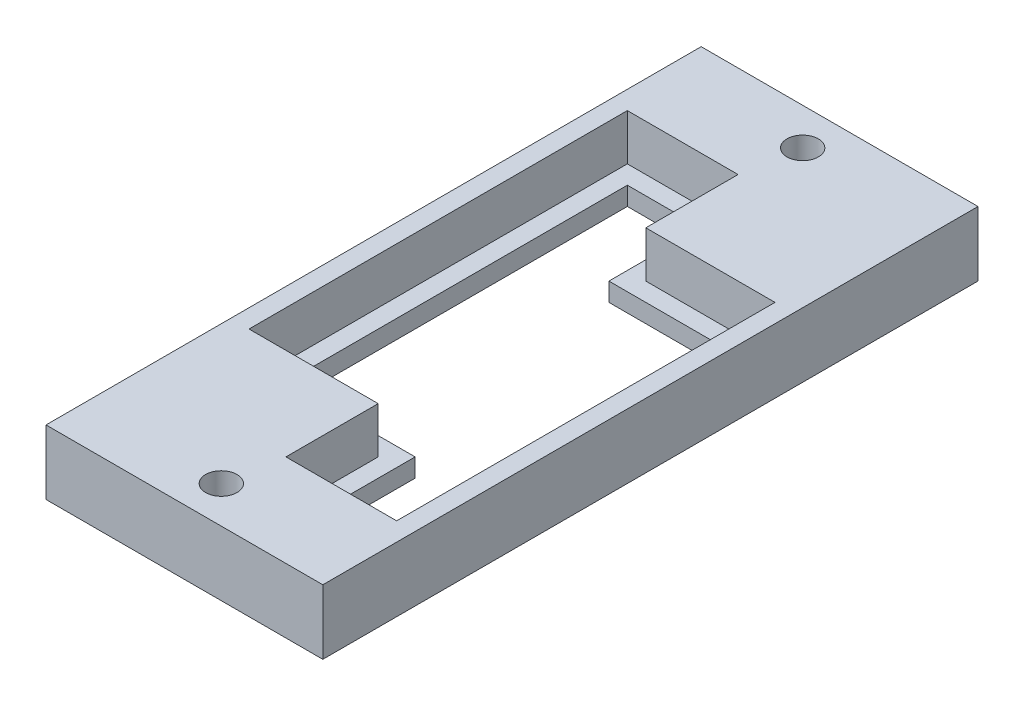
from build123d import *

# Parameters (mm, degrees)
BOSS_EXTRUDE1_DEPTH = 2
BOSS_EXTRUDE3_DEPTH = 7
SKETCH1_6_R         = 1.7
BOSS_EXTRUDE4_DEPTH = 7


with BuildPart() as part:
    # Sketch1 → Boss-Extrude1 (new body)
    with BuildSketch(Plane(origin=(0, 0, 0), x_dir=(1, 0, 0), z_dir=(0, 1, 0))):
        Polygon((-4.021978022, 18.267996412), (-16.021978022, 18.267996412), (-16.021978022, -22.732003588), (-4.021978022, -22.732003588), (-2.021978022, -22.732003588), (-2.021978022, -32.732003588), (9.978021978, -32.732003588), (9.978021978, 8.267996412), (-2.021978022, 8.267996412), (-4.021978022, 8.267996412), align=None)
        Polygon((-14.021978022, 16.267996412), (-6.021978022, 16.267996412), (-6.021978022, 6.267996412), (-2.021978022, 6.267996412), (7.978021978, 6.267996412), (7.978021978, -30.732003588), (-0.021978022, -30.732003588), (-0.021978022, -20.732003588), (-4.021978022, -20.732003588), (-14.021978022, -20.732003588), align=None, mode=Mode.SUBTRACT)
    extrude(amount=BOSS_EXTRUDE1_DEPTH)

    # Sketch1_5 → Boss-Extrude3 (add)
    with BuildSketch(Plane(origin=(0, 0, 0), x_dir=(1, 0, 0), z_dir=(0, 1, 0))):
        Polygon((-4.021978022, -34.732003588), (11.978021978, -34.732003588), (11.978021978, 10.267996412), (-2.021978022, 10.267996412), (-2.021978022, 20.267996412), (-18.021978022, 20.267996412), (-18.021978022, -24.732003588), (-4.021978022, -24.732003588), align=None)
        Polygon((-16.021978022, -22.732003588), (-16.021978022, 18.267996412), (-4.021978022, 18.267996412), (-4.021978022, 8.267996412), (-2.021978022, 8.267996412), (9.978021978, 8.267996412), (9.978021978, -32.732003588), (-2.021978022, -32.732003588), (-2.021978022, -22.732003588), (-4.021978022, -22.732003588), align=None, mode=Mode.SUBTRACT)
    extrude(amount=BOSS_EXTRUDE3_DEPTH)

    # Sketch1_6 → Boss-Extrude4 (add)
    # profile 1 of 2: a face of its own
    with BuildSketch(Plane(origin=(0, 0, 0), x_dir=(1, 0, 0), z_dir=(0, 1, 0))):
        Polygon((11.978021978, -42.732003588), (11.978021978, -34.732003588), (-4.021978022, -34.732003588), (-4.021978022, -24.732003588), (-18.021978022, -24.732003588), (-18.021978022, -42.732003588), align=None)
        with Locations((-3.021978022, -38.732003588)):
            Circle(SKETCH1_6_R, mode=Mode.SUBTRACT)
    # profile 2 of 2: a face of its own
    with BuildSketch(Plane(origin=(0, 0, 0), x_dir=(1, 0, 0), z_dir=(0, 1, 0))):
        Polygon((-2.021978022, 10.267996412), (11.978021978, 10.267996412), (11.978021978, 28.267996412), (-18.021978022, 28.267996412), (-18.021978022, 20.267996412), (-2.021978022, 20.267996412), align=None)
        with Locations((-3.021978022, 24.267996412)):
            Circle(SKETCH1_6_R, mode=Mode.SUBTRACT)
    extrude(amount=BOSS_EXTRUDE4_DEPTH)


solid = part.part
